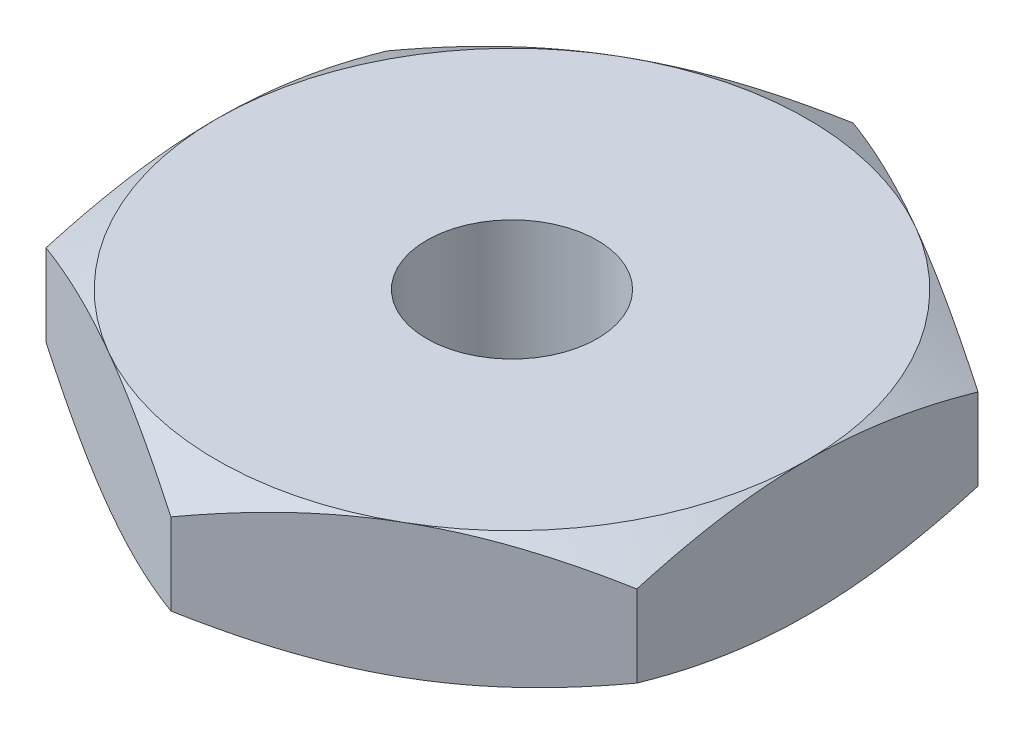
from build123d import *

# Parameters (mm, degrees)
BOSS_EXTRUDE1_DEPTH = 5
SKETCH2_R           = 6.35
CUT_EXTRUDE1_DEPTH  = 11
SKETCH3_OUTSIDE_W   = 97.688
SKETCH3_OUTSIDE_H   = 104.494
SKETCH3_OUTSIDE_R   = 21.997045256
CUT_EXTRUDE2_DEPTH  = 11
CUT_EXTRUDE2_TAPER  = 60


with BuildPart() as part:
    # Sketch1 → Boss-Extrude1 (new body, symmetric)
    with BuildSketch(Plane(origin=(0, 0, 0), x_dir=(1, 0, 0), z_dir=(0, 1, 0))):
        Polygon((21.997045256, 12.7), (0, 25.4), (-21.997045256, 12.7), (-21.997045256, -12.7), (0, -25.4), (21.997045256, -12.7), align=None)
    extrude(amount=BOSS_EXTRUDE1_DEPTH, both=True)

    # Sketch2 → Cut-Extrude1 (cut, through all)
    with BuildSketch(Plane(origin=(0, 5, 0), x_dir=(1, 0, 0), z_dir=(0, 1, 0))):
        Circle(SKETCH2_R)
    extrude(amount=-CUT_EXTRUDE1_DEPTH, mode=Mode.SUBTRACT)

    # Sketch3 outside → Cut-Extrude2 (cut, through all)
    with BuildSketch(Plane(origin=(0, 5, 0), x_dir=(1, 0, 0), z_dir=(0, 1, 0))):
        Rectangle(SKETCH3_OUTSIDE_W, SKETCH3_OUTSIDE_H)
        Circle(SKETCH3_OUTSIDE_R, mode=Mode.SUBTRACT)
    cut_extrude2 = extrude(amount=-CUT_EXTRUDE2_DEPTH, taper=CUT_EXTRUDE2_TAPER, mode=Mode.SUBTRACT)

    # Mirror1: Cut-Extrude2 across plane
    add(cut_extrude2.mirror(Plane.ZX), mode=Mode.SUBTRACT)


solid = part.part
